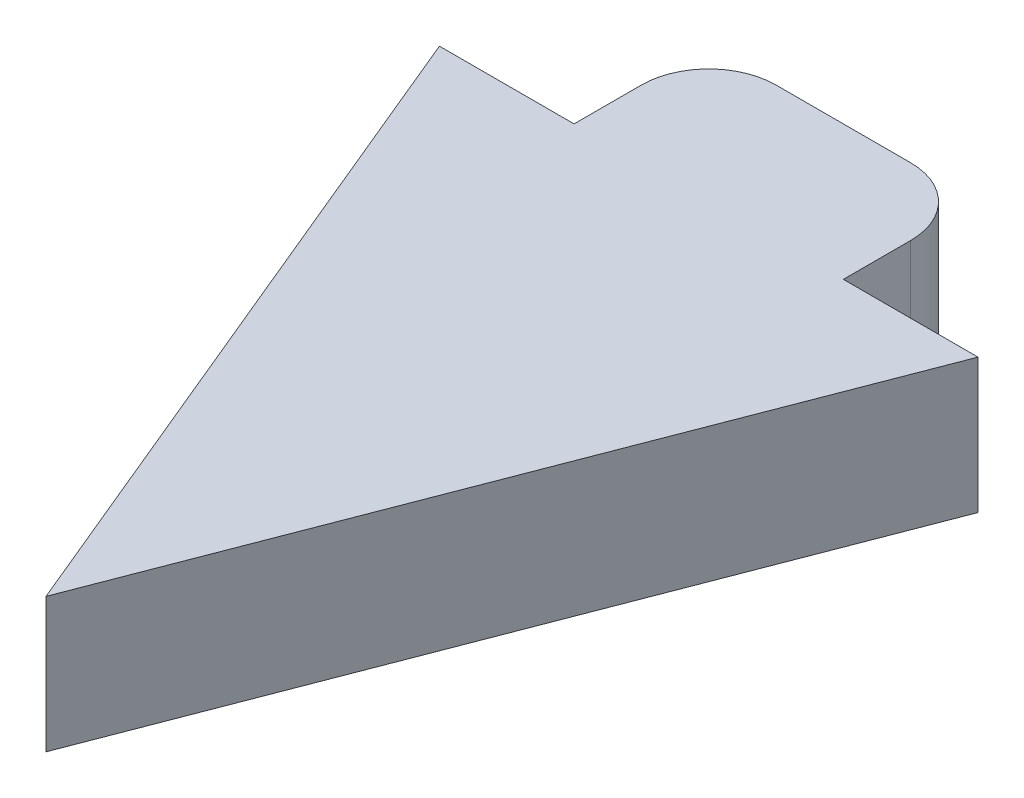
from build123d import *

# Parameters (mm, degrees)
BOSS_EXTRUDE1_DEPTH = 10
SKETCH2_R           = 3
BOSS_EXTRUDE2_DEPTH = 5
SKETCH3_R           = 1.778
CUT_EXTRUDE1_DEPTH  = 5


with BuildPart() as part:
    # Sketch1 → Boss-Extrude1 (new body)
    with BuildSketch(Plane(origin=(0, 0, 0), x_dir=(1, 0, 0), z_dir=(0, 1, 0))):
        with BuildLine():
            Line((-5.780656579, 24.018987342), (4.219343421, 24.018987342))
            ThreePointArc((4.219343421, 24.018987342), (7.754877327, 22.554521248), (9.219343421, 19.018987342))
            Line((9.219343421, 19.018987342), (9.219343421, 14.018987342))
            Line((9.219343421, 14.018987342), (19.219343421, 14.018987342))
            Line((19.219343421, 14.018987342), (0, -35.981012658))
            Line((0, -35.981012658), (-20.780656579, 14.018987342))
            Line((-20.780656579, 14.018987342), (-10.780656579, 14.018987342))
            Line((-10.780656579, 14.018987342), (-10.780656579, 19.018987342))
            ThreePointArc((-10.780656579, 19.018987342), (-9.316190485, 22.554521248), (-5.780656579, 24.018987342))
        make_face()
    extrude(amount=BOSS_EXTRUDE1_DEPTH)

    # Sketch2 → Boss-Extrude2 (add)
    with BuildSketch(Plane.XZ):
        with Locations((0.635595912, -21.018987342)):
            Circle(SKETCH2_R)
    extrude(amount=BOSS_EXTRUDE2_DEPTH)

    # Sketch3 → Cut-Extrude1 (cut)
    with BuildSketch(Plane.XZ.offset(5)):
        with Locations((0.635595912, -21.018987342)):
            Circle(SKETCH3_R)
    extrude(amount=-CUT_EXTRUDE1_DEPTH, mode=Mode.SUBTRACT)


solid = part.part
